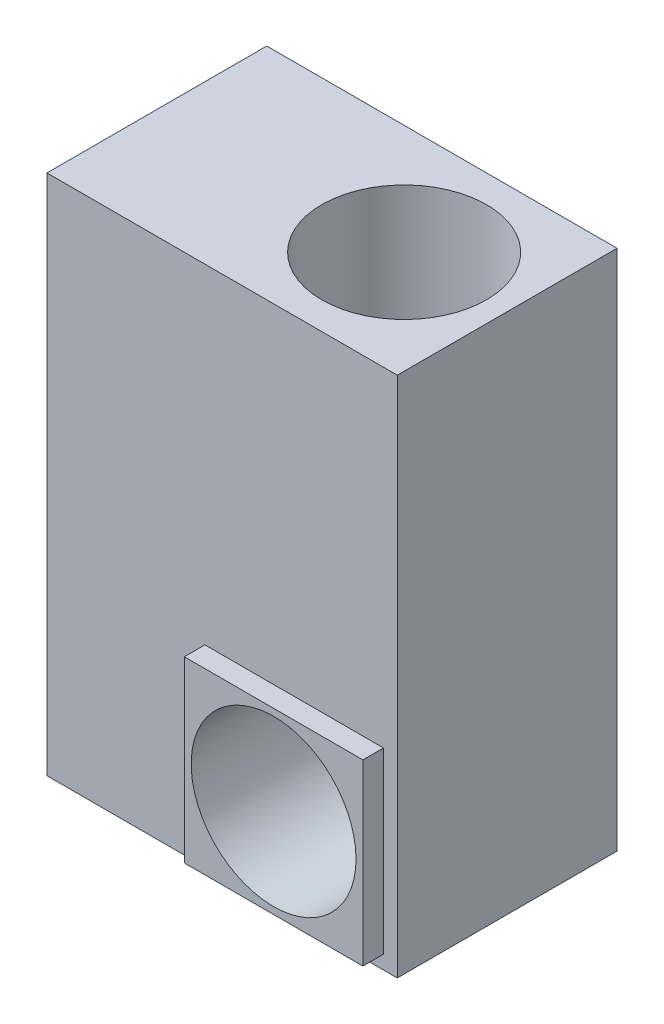
from build123d import *

# Parameters (mm, degrees)
SKETCH1_W           = 6.375
SKETCH1_H           = 9.5
BOSS_EXTRUDE1_DEPTH = 4
SCALE1_SCALE        = 25.4
SKETCH3_W           = 82.55
SKETCH3_H           = 82.55
BOSS_EXTRUDE2_DEPTH = 9.525
SKETCH4_R           = 38.1
CUT_EXTRUDE1_DEPTH  = 101.6
SKETCH5_R           = 38.1
CUT_EXTRUDE2_DEPTH  = 101.6


with BuildPart() as part:
    # Sketch1 → Boss-Extrude1 (new body)
    with BuildSketch(Plane.XY):
        with Locations((-3.1875, 4.75)):
            Rectangle(SKETCH1_W, SKETCH1_H)
    extrude(amount=BOSS_EXTRUDE1_DEPTH)


with BuildPart() as part_1:
    # Scale1: scaled about (-3.1875, 4.75, 2)
    add(part.part.scale(SCALE1_SCALE).moved(Location((77.775, -115.9, -48.8))))

    # Sketch3 → Boss-Extrude2 (add)
    with BuildSketch(Plane.XY.offset(52.8)):
        with Locations((30.15, -68.275)):
            Rectangle(SKETCH3_W, SKETCH3_H)
    extrude(amount=BOSS_EXTRUDE2_DEPTH)

    # Sketch4 → Cut-Extrude1 (cut)
    with BuildSketch(Plane.XY.offset(62.325)):
        with Locations((30.15, -68.275)):
            Circle(SKETCH4_R)
    extrude(amount=-CUT_EXTRUDE1_DEPTH, mode=Mode.SUBTRACT)

    # Sketch5 → Cut-Extrude2 (cut)
    with BuildSketch(Plane(origin=(0, 125.4, 0), x_dir=(1, 0, 0), z_dir=(0, 1, 0))):
        with Locations((30.15, -2)):
            Circle(SKETCH5_R)
    extrude(amount=-CUT_EXTRUDE2_DEPTH, mode=Mode.SUBTRACT)


solid = part_1.part
